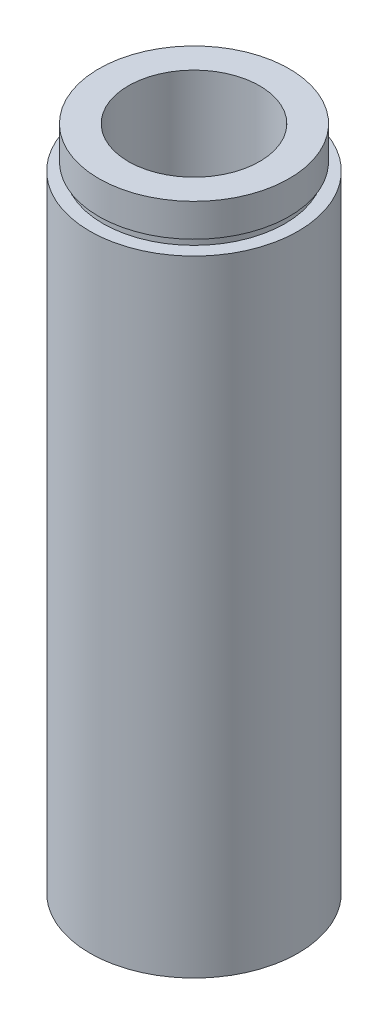
from build123d import *


with BuildPart() as part:
    # 草图1 → 旋转1 (revolve)
    with BuildSketch(Plane.XY, mode=Mode.PRIVATE) as revolve_1_sk:
        Polygon((11.1, 0), (11.1, 4.5), (11.7, 4.5), (11.7, 5.5), (8, 5.5), (8, 81.2), (11.6, 81.2), (11.6, 77.2), (11.1, 77.2), (11.1, 76.2), (12.7, 76.2), (12.7, 0), align=None)
    revolve(revolve_1_sk.sketch.rotate(Axis((0, 161.376166943, 0), (0, -1, 0)), 90), axis=Axis((0, 161.376166943, 0), (0, -1, 0)))  # turned: the seam where the file's is


solid = part.part
